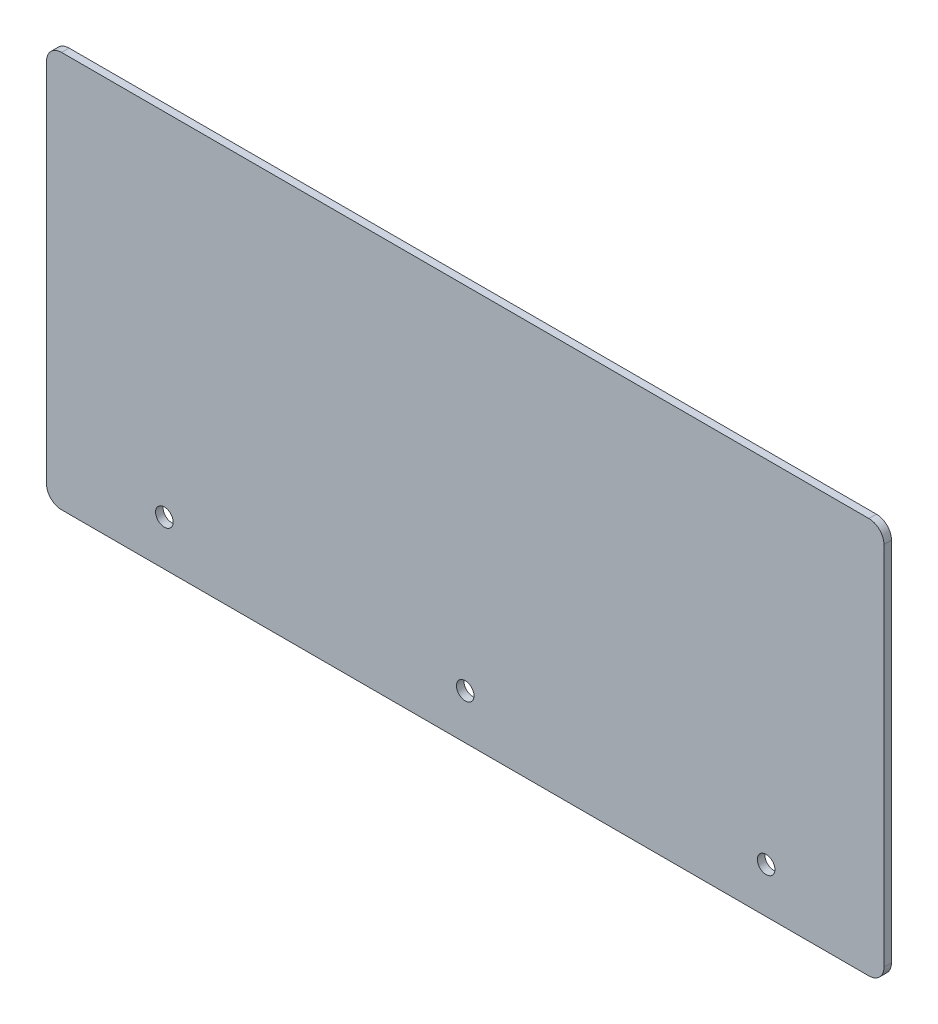
from build123d import *

# Parameters (mm, degrees)
ESQUISSE1_W                  = 167
ESQUISSE1_H                  = 79
BOSS_EXTRU_1_DEPTH           = 1.5
CONG_1_R                     = 3
ESQUISSE2_R                  = 1.75
ENL_V_MAT_EXTRU_1_DEPTH      = 1
ENL_V_MAT_EXTRU_1_DEPTH_BACK = 2.5


with BuildPart() as part:
    # Esquisse1 → Boss.-Extru.1 (new body)
    with BuildSketch(Plane.XY):
        with Locations((83.5, 39.5)):
            Rectangle(ESQUISSE1_W, ESQUISSE1_H)
    extrude(amount=BOSS_EXTRU_1_DEPTH)

    # Congé1
    cong_1_edges = [part.edges().sort_by_distance(p)[0] for p in [
        (0, 79, 0.75),
        (167, 79, 0.75),
        (167, 0, 0.75),
        (0, 0, 0.75),
    ]]
    fillet(cong_1_edges, radius=CONG_1_R)

    # Esquisse2 → Enlèv. mat.-Extru.1 (cut, two sides)
    with BuildSketch(Plane.XY.offset(1.5)) as enl_v_mat_extru_1_sk:
        with Locations((23.5, 9)):
            Circle(ESQUISSE2_R)
        with Locations((83.5, 9)):
            Circle(ESQUISSE2_R)
        with Locations((143.5, 9)):
            Circle(ESQUISSE2_R)
    extrude(amount=ENL_V_MAT_EXTRU_1_DEPTH, mode=Mode.SUBTRACT)
    extrude(enl_v_mat_extru_1_sk.sketch, amount=-ENL_V_MAT_EXTRU_1_DEPTH_BACK, mode=Mode.SUBTRACT)


solid = part.part
